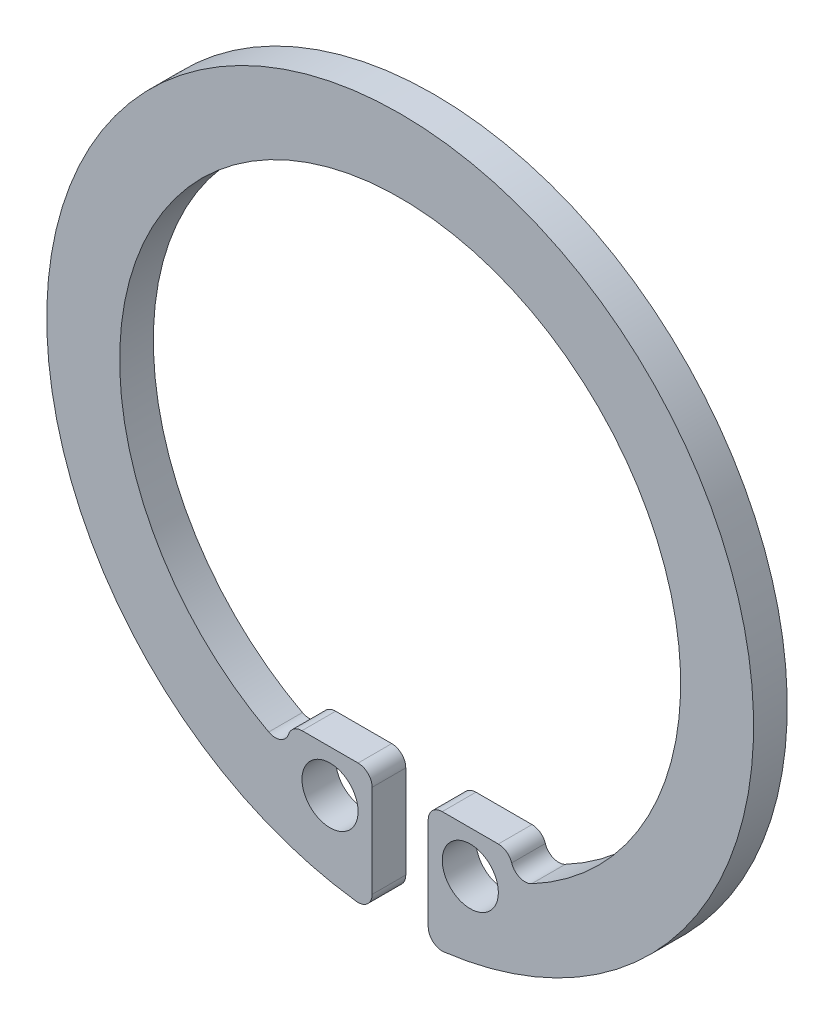
from build123d import *

# Parameters (mm, degrees)
SZKIC1_R                    = 1
DODANIE_WYCI_GNI_CIE1_DEPTH = 1.2
ZAOKR_GLENIE2_R             = 0.5
ZAOKR_GLENIE3_R             = 0.5
ZAOKR_GLENIE4_R             = 0.5
ZAOKR_GLENIE5_R             = 0.5
ZAOKR_GLENIE6_R             = 0.5
ZAOKR_GLENIE7_R             = 0.5
ZAOKR_GLENIE8_R             = 0.5
ZAOKR_GLENIE9_R             = 0.5


with BuildPart() as part:
    # Szkic1 → Dodanie-wyciągnięcie1 (new body)
    with BuildSketch(Plane.XY):
        with BuildLine():
            Line((-1, -12.560254774), (-1, -8.2))
            Line((-1, -8.2), (-4, -8.2))
            Line((-4, -8.2), (-4, -9.16515139))
            ThreePointArc((-4, -9.16515139), (0, 10), (4, -9.16515139))
            Line((4, -9.16515139), (4, -8.2))
            Line((4, -8.2), (1, -8.2))
            Line((1, -8.2), (1, -12.560254774))
            ThreePointArc((1, -12.560254774), (0, 12.6), (-1, -12.560254774))
        make_face()
        with Locations((2.5, -9.7)):
            Circle(SZKIC1_R, mode=Mode.SUBTRACT)
        with Locations((-2.5, -9.7)):
            Circle(SZKIC1_R, mode=Mode.SUBTRACT)
    extrude(amount=DODANIE_WYCI_GNI_CIE1_DEPTH)

    # Zaokrąglenie2
    zaokr_glenie2_edges = [part.edges().sort_by_distance(p)[0] for p in [
        (1, -12.560254774, 0.6),
    ]]
    fillet(zaokr_glenie2_edges, radius=ZAOKR_GLENIE2_R)

    # Zaokrąglenie3
    zaokr_glenie3_edges = [part.edges().sort_by_distance(p)[0] for p in [
        (-1, -12.560254774, 0.6),
    ]]
    fillet(zaokr_glenie3_edges, radius=ZAOKR_GLENIE3_R)

    # Zaokrąglenie4
    zaokr_glenie4_edges = [part.edges().sort_by_distance(p)[0] for p in [
        (1, -8.2, 0.6),
    ]]
    fillet(zaokr_glenie4_edges, radius=ZAOKR_GLENIE4_R)

    # Zaokrąglenie5
    zaokr_glenie5_edges = [part.edges().sort_by_distance(p)[0] for p in [
        (4, -8.2, 0.6),
    ]]
    fillet(zaokr_glenie5_edges, radius=ZAOKR_GLENIE5_R)

    # Zaokrąglenie6
    zaokr_glenie6_edges = [part.edges().sort_by_distance(p)[0] for p in [
        (4, -9.16515139, 0.6),
    ]]
    fillet(zaokr_glenie6_edges, radius=ZAOKR_GLENIE6_R)

    # Zaokrąglenie7
    zaokr_glenie7_edges = [part.edges().sort_by_distance(p)[0] for p in [
        (-4, -8.2, 0.6),
    ]]
    fillet(zaokr_glenie7_edges, radius=ZAOKR_GLENIE7_R)

    # Zaokrąglenie8
    zaokr_glenie8_edges = [part.edges().sort_by_distance(p)[0] for p in [
        (-1, -8.2, 0.6),
    ]]
    fillet(zaokr_glenie8_edges, radius=ZAOKR_GLENIE8_R)

    # Zaokrąglenie9
    zaokr_glenie9_edges = [part.edges().sort_by_distance(p)[0] for p in [
        (-4, -9.16515139, 0.6),
    ]]
    fillet(zaokr_glenie9_edges, radius=ZAOKR_GLENIE9_R)


solid = part.part
